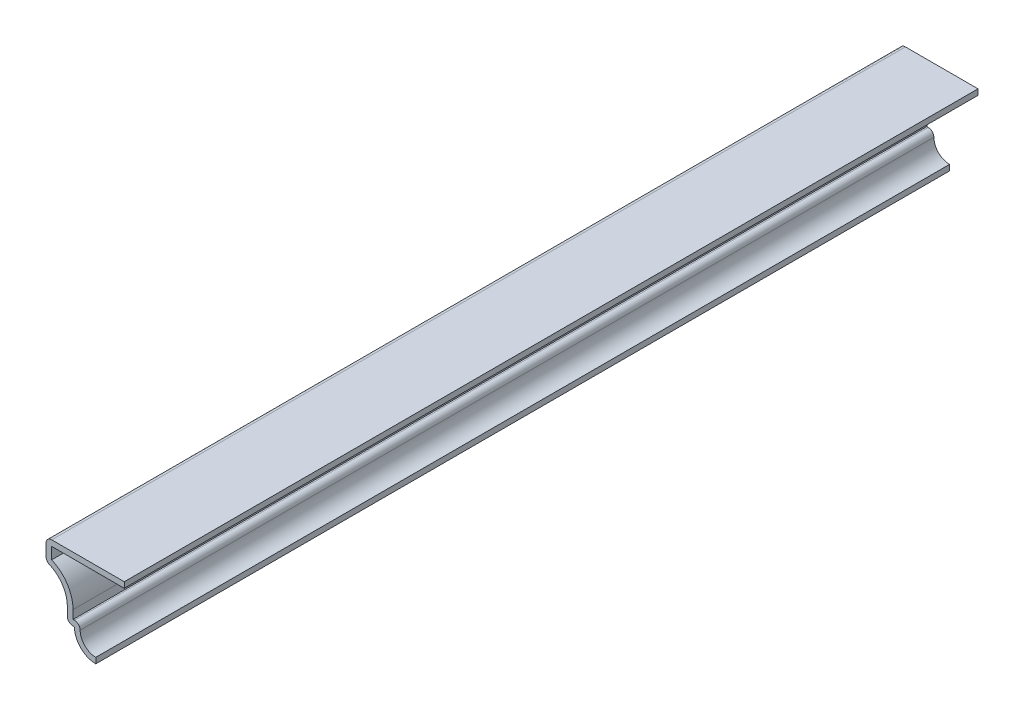
from build123d import *

# Parameters (mm, degrees)
EXTRUDE_THIN1_DEPTH = 190.5
FILLET1_R           = 1.27


with BuildPart() as part:
    # Sketch1 → Extrude-Thin1 (new body)
    with BuildSketch(Plane.XY):
        with BuildLine():
            Line((6.35, 19.05), (-11.1125, 19.05))
            Line((-11.1125, 19.05), (-11.1125, 14.2875))
            ThreePointArc((-11.1125, 14.2875), (-7.672916667, 11.90625), (-6.35, 7.9375))
            Line((-6.35, 7.9375), (-6.35, 4.7625))
            Line((-6.35, 4.7625), (-4.7625, 4.7625))
            ThreePointArc((-4.7625, 4.7625), (-3.367596045, 1.394903955), (0, 0))
            Line((0, 0), (0, 1.27))
            ThreePointArc((0, 1.27), (-2.883836962, 2.792464309), (-3.253406868, 6.0325))
            Line((-3.253406868, 6.0325), (-5.08, 6.0325))
            Line((-5.08, 6.0325), (-5.08, 7.9375))
            ThreePointArc((-5.08, 7.9375), (-6.377361591, 12.27053174), (-9.8425, 15.177613949))
            Line((-9.8425, 15.177613949), (-9.8425, 17.78))
            Line((-9.8425, 17.78), (6.35, 17.78))
            Line((6.35, 17.78), (6.35, 19.05))
        make_face()
    extrude(amount=-EXTRUDE_THIN1_DEPTH)

    # Fillet1
    fillet1_edges = [part.edges().sort_by_distance(p)[0] for p in [
        (-6.35, 4.7625, -95.25),
        (-11.1125, 14.2875, -95.25),
        (-11.1125, 19.05, -95.25),
        (-3.253406868, 6.0325, -95.25),
    ]]
    fillet(fillet1_edges, radius=FILLET1_R)


solid = part.part
